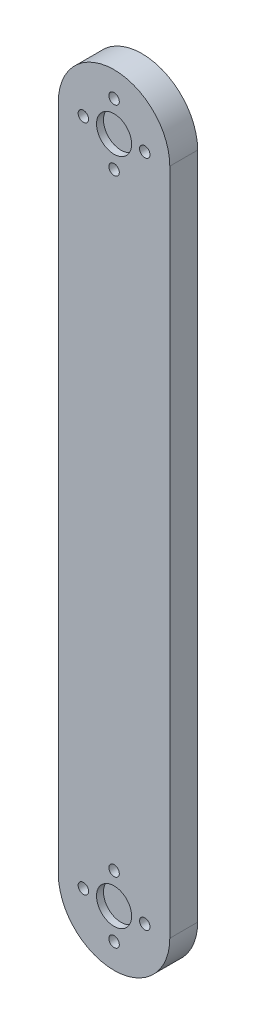
from build123d import *

# Parameters (mm, degrees)
BOSS_EXTRUDE1_DEPTH          = 6.35
SKETCH2_R                    = 4
CUT_EXTRUDE1_DEPTH           = 1.5875
SKETCH3_R                    = 1.190625
CUT_EXTRUDE2_DEPTH           = 6.35
CIRPATTERN1_COUNT            = 4
CIRPATTERN2_COPY_1_SKETCH_R  = 1.190625
CIRPATTERN2_COPY_1_DEPTH     = 6.35
CIRPATTERN2_COPY_2_SKETCH_R  = 1.190625
CIRPATTERN2_COPY_2_DEPTH     = 6.35
CIRPATTERN2_COPY_3_SKETCH_R  = 1.190625
CIRPATTERN2_COPY_3_DEPTH     = 6.35
CIRPATTERN2_COPY_4_SKETCH_R  = 1.190625
CIRPATTERN2_COPY_4_DEPTH     = 6.35
CIRPATTERN2_COPY_5_SKETCH_R  = 1.190625
CIRPATTERN2_COPY_5_DEPTH     = 6.35
CIRPATTERN2_COPY_6_SKETCH_R  = 1.190625
CIRPATTERN2_COPY_6_DEPTH     = 6.35
CIRPATTERN2_COPY_7_SKETCH_R  = 1.190625
CIRPATTERN2_COPY_7_DEPTH     = 6.35
CIRPATTERN2_COPY_8_SKETCH_R  = 1.190625
CIRPATTERN2_COPY_8_DEPTH     = 6.35
CIRPATTERN2_COPY_9_SKETCH_R  = 1.190625
CIRPATTERN2_COPY_9_DEPTH     = 6.35
CIRPATTERN2_COPY_10_SKETCH_R = 1.190625
CIRPATTERN2_COPY_10_DEPTH    = 6.35
CIRPATTERN2_COPY_11_SKETCH_R = 1.190625
CIRPATTERN2_COPY_11_DEPTH    = 6.35
CIRPATTERN2_COPY_12_SKETCH_R = 1.190625
CIRPATTERN2_COPY_12_DEPTH    = 6.35


with BuildPart() as part:
    # Sketch1 → Boss-Extrude1 (new body)
    with BuildSketch(Plane.XY):
        with BuildLine():
            Line((-12.7, -76.2), (-12.7, 76.2))
            ThreePointArc((-12.7, 76.2), (0, 88.9), (12.7, 76.2))
            Line((12.7, 76.2), (12.7, -76.2))
            ThreePointArc((12.7, -76.2), (0, -88.9), (-12.7, -76.2))
        make_face()
    extrude(amount=BOSS_EXTRUDE1_DEPTH)

    # Sketch2 → Cut-Extrude1 (cut)
    with BuildSketch(Plane.XY.offset(6.35)):
        with Locations((0, 76.2)):
            Circle(SKETCH2_R)
    cut_extrude1 = extrude(amount=-CUT_EXTRUDE1_DEPTH, mode=Mode.SUBTRACT)

    # Mirror1: Cut-Extrude1 across plane
    add(cut_extrude1.mirror(Plane.ZX), mode=Mode.SUBTRACT)

    # Sketch3 → Cut-Extrude2 (cut)
    with BuildSketch(Plane.XY.offset(6.35)):
        with Locations((0, 83.2)):
            Circle(SKETCH3_R)
        with Locations((0, -69.2)):
            Circle(SKETCH3_R)
    cut_extrude2 = extrude(amount=-CUT_EXTRUDE2_DEPTH, mode=Mode.SUBTRACT)

    # CirPattern1: Cut-Extrude2 ×4 about axis
    cirpattern1_axis = Axis((0, 76.2, 0), (0, 0, 1))
    for i in range(1, CIRPATTERN1_COUNT):
        add(cut_extrude2.rotate(cirpattern1_axis, i * 360 / CIRPATTERN1_COUNT), mode=Mode.SUBTRACT)

    # CirPattern2 copy 1 sketch → CirPattern2 copy 1 (cut)
    with BuildSketch(Plane(origin=(-152.4, 0, 6.35), x_dir=(-1, 0, 0), z_dir=(0, 0, 1))):
        with Locations((0, 83.2)):
            Circle(CIRPATTERN2_COPY_1_SKETCH_R)
        with Locations((0, -69.2)):
            Circle(CIRPATTERN2_COPY_1_SKETCH_R)
    extrude(amount=-CIRPATTERN2_COPY_1_DEPTH, mode=Mode.SUBTRACT)

    # CirPattern2 copy 2 sketch → CirPattern2 copy 2 (cut)
    with BuildSketch(Plane(origin=(-76.2, -228.6, 6.35), x_dir=(0, -1, 0), z_dir=(0, 0, 1))):
        with Locations((0, 83.2)):
            Circle(CIRPATTERN2_COPY_2_SKETCH_R)
        with Locations((0, -69.2)):
            Circle(CIRPATTERN2_COPY_2_SKETCH_R)
    extrude(amount=-CIRPATTERN2_COPY_2_DEPTH, mode=Mode.SUBTRACT)

    # CirPattern2 copy 3 sketch → CirPattern2 copy 3 (cut)
    with BuildSketch(Plane(origin=(152.4, -152.4, 6.35), x_dir=(1, 0, 0), z_dir=(0, 0, 1))):
        with Locations((0, 83.2)):
            Circle(CIRPATTERN2_COPY_3_SKETCH_R)
        with Locations((0, -69.2)):
            Circle(CIRPATTERN2_COPY_3_SKETCH_R)
    extrude(amount=-CIRPATTERN2_COPY_3_DEPTH, mode=Mode.SUBTRACT)

    # CirPattern2 copy 4 sketch → CirPattern2 copy 4 (cut)
    with BuildSketch(Plane(origin=(-228.6, -76.2, 6.35), x_dir=(0, -1, 0), z_dir=(0, 0, 1))):
        with Locations((0, 83.2)):
            Circle(CIRPATTERN2_COPY_4_SKETCH_R)
        with Locations((0, -69.2)):
            Circle(CIRPATTERN2_COPY_4_SKETCH_R)
    extrude(amount=-CIRPATTERN2_COPY_4_DEPTH, mode=Mode.SUBTRACT)

    # CirPattern2 copy 5 sketch → CirPattern2 copy 5 (cut)
    with BuildSketch(Plane(origin=(0, -304.8, 6.35), x_dir=(1, 0, 0), z_dir=(0, 0, 1))):
        with Locations((0, 83.2)):
            Circle(CIRPATTERN2_COPY_5_SKETCH_R)
        with Locations((0, -69.2)):
            Circle(CIRPATTERN2_COPY_5_SKETCH_R)
    extrude(amount=-CIRPATTERN2_COPY_5_DEPTH, mode=Mode.SUBTRACT)

    # CirPattern2 copy 6 sketch → CirPattern2 copy 6 (cut)
    with BuildSketch(Plane(origin=(228.6, -76.2, 6.35), x_dir=(0, 1, 0), z_dir=(0, 0, 1))):
        with Locations((0, 83.2)):
            Circle(CIRPATTERN2_COPY_6_SKETCH_R)
        with Locations((0, -69.2)):
            Circle(CIRPATTERN2_COPY_6_SKETCH_R)
    extrude(amount=-CIRPATTERN2_COPY_6_DEPTH, mode=Mode.SUBTRACT)

    # CirPattern2 copy 7 sketch → CirPattern2 copy 7 (cut)
    with BuildSketch(Plane(origin=(-152.4, -152.4, 6.35), x_dir=(1, 0, 0), z_dir=(0, 0, 1))):
        with Locations((0, 83.2)):
            Circle(CIRPATTERN2_COPY_7_SKETCH_R)
        with Locations((0, -69.2)):
            Circle(CIRPATTERN2_COPY_7_SKETCH_R)
    extrude(amount=-CIRPATTERN2_COPY_7_DEPTH, mode=Mode.SUBTRACT)

    # CirPattern2 copy 8 sketch → CirPattern2 copy 8 (cut)
    with BuildSketch(Plane(origin=(76.2, -228.6, 6.35), x_dir=(0, 1, 0), z_dir=(0, 0, 1))):
        with Locations((0, 83.2)):
            Circle(CIRPATTERN2_COPY_8_SKETCH_R)
        with Locations((0, -69.2)):
            Circle(CIRPATTERN2_COPY_8_SKETCH_R)
    extrude(amount=-CIRPATTERN2_COPY_8_DEPTH, mode=Mode.SUBTRACT)

    # CirPattern2 copy 9 sketch → CirPattern2 copy 9 (cut)
    with BuildSketch(Plane(origin=(152.4, 0, 6.35), x_dir=(-1, 0, 0), z_dir=(0, 0, 1))):
        with Locations((0, 83.2)):
            Circle(CIRPATTERN2_COPY_9_SKETCH_R)
        with Locations((0, -69.2)):
            Circle(CIRPATTERN2_COPY_9_SKETCH_R)
    extrude(amount=-CIRPATTERN2_COPY_9_DEPTH, mode=Mode.SUBTRACT)

    # CirPattern2 copy 10 sketch → CirPattern2 copy 10 (cut)
    with BuildSketch(Plane(origin=(-76.2, -76.2, 6.35), x_dir=(0, 1, 0), z_dir=(0, 0, 1))):
        with Locations((0, 83.2)):
            Circle(CIRPATTERN2_COPY_10_SKETCH_R)
        with Locations((0, -69.2)):
            Circle(CIRPATTERN2_COPY_10_SKETCH_R)
    extrude(amount=-CIRPATTERN2_COPY_10_DEPTH, mode=Mode.SUBTRACT)

    # CirPattern2 copy 11 sketch → CirPattern2 copy 11 (cut)
    with BuildSketch(Plane(origin=(0, -152.4, 6.35), x_dir=(-1, 0, 0), z_dir=(0, 0, 1))):
        with Locations((0, 83.2)):
            Circle(CIRPATTERN2_COPY_11_SKETCH_R)
        with Locations((0, -69.2)):
            Circle(CIRPATTERN2_COPY_11_SKETCH_R)
    extrude(amount=-CIRPATTERN2_COPY_11_DEPTH, mode=Mode.SUBTRACT)

    # CirPattern2 copy 12 sketch → CirPattern2 copy 12 (cut)
    with BuildSketch(Plane(origin=(76.2, -76.2, 6.35), x_dir=(0, -1, 0), z_dir=(0, 0, 1))):
        with Locations((0, 83.2)):
            Circle(CIRPATTERN2_COPY_12_SKETCH_R)
        with Locations((0, -69.2)):
            Circle(CIRPATTERN2_COPY_12_SKETCH_R)
    extrude(amount=-CIRPATTERN2_COPY_12_DEPTH, mode=Mode.SUBTRACT)


solid = part.part
